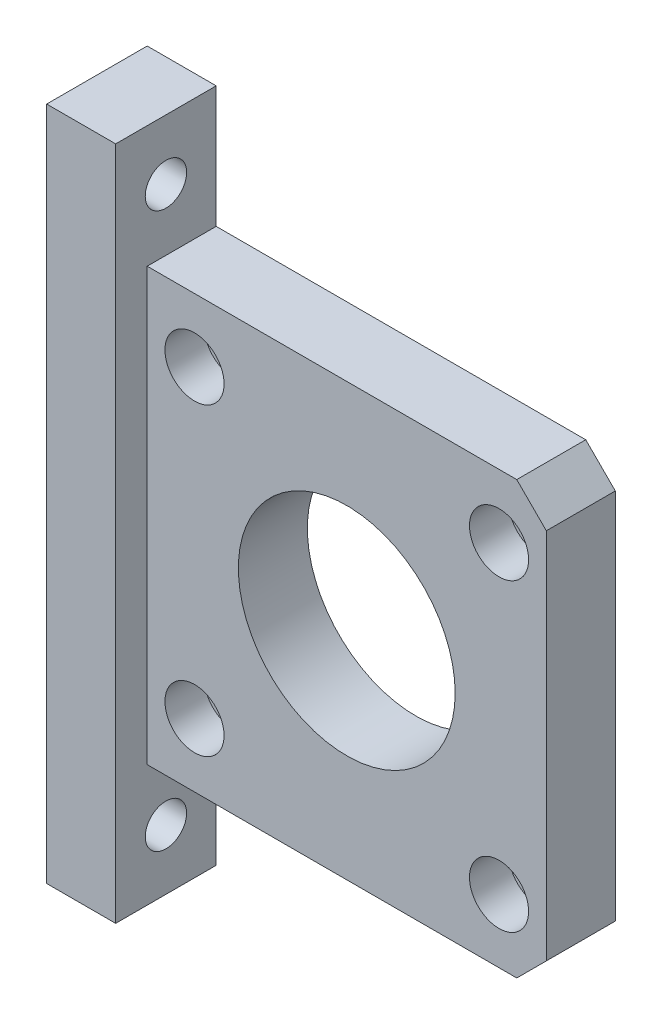
from build123d import *

# Parameters (mm, degrees)
CROQUIS1_R              = 11
CROQUIS1_R_2            = 1.75
SALIENTE_EXTRUIR1_DEPTH = 7
CROQUIS2_R              = 3
CORTAR_EXTRUIR1_DEPTH   = 4
CROQUIS3_W              = 7
CROQUIS3_H              = 68.5
SALIENTE_EXTRUIR2_DEPTH = 10.2
CROQUIS4_R              = 2.1
CORTAR_EXTRUIR2_DEPTH   = 7


with BuildPart() as part:
    # Croquis1 → Saliente-Extruir1 (new body)
    with BuildSketch(Plane.XY):
        Polygon((17.25, -21.9), (20.25, -18.9), (20.25, 18.9), (17.25, 21.9), (-20.25, 21.9), (-20.25, -21.9), align=None)
        Circle(CROQUIS1_R, mode=Mode.SUBTRACT)
        with Locations((15.450283169, 15.450283169)):
            Circle(CROQUIS1_R_2, mode=Mode.SUBTRACT)
        with Locations((15.450283169, -15.450283169)):
            Circle(CROQUIS1_R_2, mode=Mode.SUBTRACT)
        with Locations((-15.450283169, -15.450283169)):
            Circle(CROQUIS1_R_2, mode=Mode.SUBTRACT)
        with Locations((-15.450283169, 15.450283169)):
            Circle(CROQUIS1_R_2, mode=Mode.SUBTRACT)
    extrude(amount=SALIENTE_EXTRUIR1_DEPTH)

    # Croquis2 → Cortar-Extruir1 (cut)
    with BuildSketch(Plane.XY.offset(7)):
        with Locations((15.450283169, 15.450283169)):
            Circle(CROQUIS2_R)
        with Locations((15.450283169, -15.450283169)):
            Circle(CROQUIS2_R)
        with Locations((-15.450283169, -15.450283169)):
            Circle(CROQUIS2_R)
        with Locations((-15.450283169, 15.450283169)):
            Circle(CROQUIS2_R)
    extrude(amount=-CORTAR_EXTRUIR1_DEPTH, mode=Mode.SUBTRACT)

    # Croquis3 → Saliente-Extruir2 (add)
    with BuildSketch(Plane(origin=(0, 0, 0), x_dir=(-1, 0, 0), z_dir=(0, 0, -1))):
        with Locations((23.75, 0)):
            Rectangle(CROQUIS3_W, CROQUIS3_H)
    extrude(amount=-SALIENTE_EXTRUIR2_DEPTH)

    # Croquis4 → Cortar-Extruir2 (cut)
    with BuildSketch(Plane.ZY.offset(27.25)):
        with Locations((5.1, 28.15)):
            Circle(CROQUIS4_R)
        with Locations((5.1, -28.15)):
            Circle(CROQUIS4_R)
    extrude(amount=-CORTAR_EXTRUIR2_DEPTH, mode=Mode.SUBTRACT)


solid = part.part
